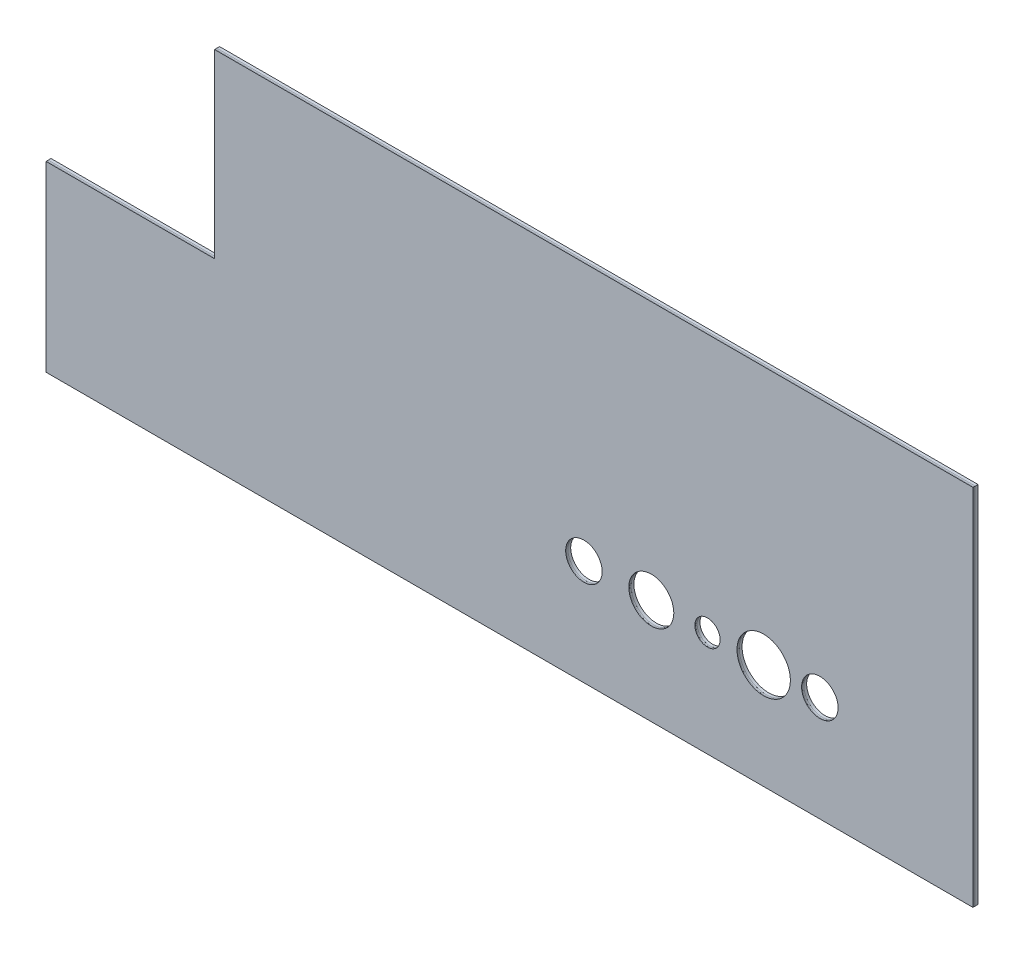
from build123d import *

# Parameters (mm, degrees)
DODANIE_WYCI_GNI_CIE1_DEPTH = 1
DODANIE_WYCI_GNI_CIE2_DEPTH = 0.5
DODANIE_WYCI_GNI_CIE3_DEPTH = 0.3
SZKIC4_R                    = 9.5
SZKIC4_R_2                  = 4.5
SZKIC4_R_3                  = 8
SZKIC4_R_4                  = 6.5
WYTNIJ_WYCI_GNI_CIE1_DEPTH  = 2.8


with BuildPart() as part:
    # Szkic1 → Dodanie-wyciągnięcie1 (new body)
    with BuildSketch(Plane.XY):
        Polygon((0, 0), (0, 129.5), (-270, 129.5), (-270, 65), (-330, 65), (-330, 0), align=None)
    extrude(amount=DODANIE_WYCI_GNI_CIE1_DEPTH)


with BuildPart() as body_2:
    # Szkic2 → Dodanie-wyciągnięcie2 (new body)
    with BuildSketch(Plane.XY.offset(1)):
        Polygon((0, 0), (-330, 0), (-330, 65), (-270, 65), (-270, 129.5), (0, 129.5), align=None)
    extrude(amount=DODANIE_WYCI_GNI_CIE2_DEPTH)


with BuildPart() as body_3:
    # Szkic3 → Dodanie-wyciągnięcie3 (new body)
    with BuildSketch(Plane.XY.offset(1.5)):
        Polygon((0, 0), (0, 129.5), (-270, 129.5), (-270, 65), (-330, 65), (-330, 0), align=None)
    extrude(amount=DODANIE_WYCI_GNI_CIE3_DEPTH)


with BuildPart() as wytnij_wyci_gni_cie1_tool:
    # Szkic4 → Wytnij-wyciągnięcie1 (new body, through all)
    with BuildSketch(Plane.XY.offset(1.8)):
        with Locations((-74.5, 37.5)):
            Circle(SZKIC4_R)
        with Locations((-94.5, 37.5)):
            Circle(SZKIC4_R_2)
        with Locations((-114.5, 37.5)):
            Circle(SZKIC4_R_3)
        with Locations((-138.5, 37.5)):
            Circle(SZKIC4_R_4)
        with Locations((-54.5, 37.5)):
            Circle(SZKIC4_R_4)
    extrude(amount=-WYTNIJ_WYCI_GNI_CIE1_DEPTH)


with BuildPart() as part_1:
    add(part.part)

    # Wytnij-wyciągnięcie1: cut by wytnij_wyci_gni_cie1_tool
    add(wytnij_wyci_gni_cie1_tool.part, mode=Mode.SUBTRACT)


with BuildPart() as body_2_1:
    add(body_2.part)

    # Wytnij-wyciągnięcie1: cut by wytnij_wyci_gni_cie1_tool
    add(wytnij_wyci_gni_cie1_tool.part, mode=Mode.SUBTRACT)


with BuildPart() as body_3_1:
    add(body_3.part)

    # Wytnij-wyciągnięcie1: cut by wytnij_wyci_gni_cie1_tool
    add(wytnij_wyci_gni_cie1_tool.part, mode=Mode.SUBTRACT)


solid = Compound([part_1.part, body_2_1.part, body_3_1.part])
